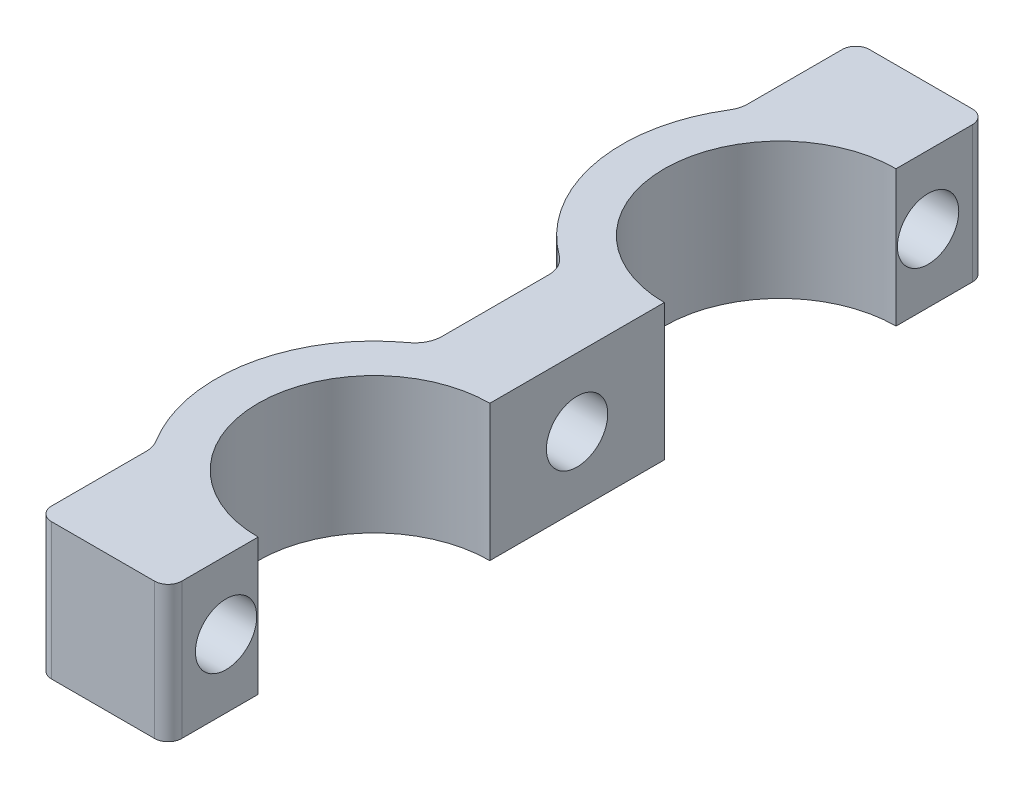
from build123d import *

# Parameters (mm, degrees)
EXTRUDE_1_DEPTH     = 10
EXTRUDE_2_DEPTH     = 10
EXTRUDE_4_DEPTH     = 10
SKETCH_3_R          = 2.25
CUT_EXTRUDE_4_DEPTH = 12.6
SKETCH_4_R          = 2.25
CUT_EXTRUDE_2_DEPTH = 7
FILLET_2_R          = 1
EXTRUDE_3_DEPTH     = 10
CUT_EXTRUDE_3_DEPTH = 11
FILLET_3_R          = 1
FILLET_4_R          = 2


with BuildPart() as part:
    # Эскиз1 → Бобышка-Вытянуть1 (new body)
    with BuildSketch(Plane(origin=(0, 0, 0), x_dir=(1, 0, 0), z_dir=(0, 1, 0))):
        with BuildLine():
            Line((0, 0), (0, 8))
            ThreePointArc((0, 8), (-7.1, 15.1), (0, 22.2))
            Line((0, 22.2), (0, 37.8))
            ThreePointArc((0, 37.8), (-7.1, 44.9), (0, 52))
            Line((0, 52), (0, 60))
            Line((0, 60), (-3, 60))
            Line((-3, 60), (-3, 54.544169223))
            ThreePointArc((-3, 54.544169223), (-10.1, 44.9), (-3, 35.255830777))
            Line((-3, 35.255830777), (-3, 24.744169223))
            ThreePointArc((-3, 24.744169223), (-10.1, 15.1), (-3, 5.455830777))
            Line((-3, 5.455830777), (-3, 0))
            Line((-3, 0), (0, 0))
        make_face()
    extrude(amount=EXTRUDE_1_DEPTH)

    # Эскиз2 → Бобышка-Вытянуть2 (add)
    with BuildSketch(Plane(origin=(0, 10, 0), x_dir=(1, 0, 0), z_dir=(0, 1, 0))):
        with BuildLine():
            Line((-3, 60), (-8.049844719, 60))
            Line((-8.049844719, 60), (-8.049844719, 51))
            ThreePointArc((-8.049844719, 51), (-5.802159163, 53.167100402), (-3, 54.544169223))
            Line((-3, 54.544169223), (-3, 60))
        make_face()
        with BuildLine():
            Line((-3, 0), (-3, 5.455830777))
            ThreePointArc((-3, 5.455830777), (-5.802159163, 6.832899598), (-8.049844719, 9))
            Line((-8.049844719, 9), (-8.049844719, 0))
            Line((-8.049844719, 0), (-3, 0))
        make_face()
    extrude(amount=-EXTRUDE_2_DEPTH)

    # Эскиз9 → Бобышка-Вытянуть4 (add, through all)
    with BuildSketch(Plane.XZ):
        with BuildLine():
            Line((-6, -25.027738917), (-6, -34.972261083))
            ThreePointArc((-6, -34.972261083), (-11.340897297, -42.461958059), (-9.549844719, -51.484866426))
            Line((-9.549844719, -51.484866426), (-9.549844719, -60))
            Line((-9.549844719, -60), (-8.049844719, -60))
            Line((-8.049844719, -60), (-8.049844719, -51))
            ThreePointArc((-8.049844719, -51), (-9.617405222, -41.81527687), (-3, -35.255830777))
            Line((-3, -35.255830777), (-3, -24.744169223))
            ThreePointArc((-3, -24.744169223), (-9.617405222, -18.18472313), (-8.049844719, -9))
            Line((-8.049844719, -9), (-8.049844719, 0))
            Line((-8.049844719, 0), (-9.549844719, 0))
            Line((-9.549844719, 0), (-9.549844719, -8.515133574))
            ThreePointArc((-9.549844719, -8.515133574), (-11.340897297, -17.538041941), (-6, -25.027738917))
        make_face()
    extrude(amount=-EXTRUDE_4_DEPTH)

    # Эскиз3 → Вырез-Вытянуть4 (cut, through all)
    with BuildSketch(Plane.ZY):
        with Locations((-55.75, 5)):
            Circle(SKETCH_3_R)
        with Locations((-4.25, 5)):
            Circle(SKETCH_3_R)
    extrude(amount=CUT_EXTRUDE_4_DEPTH, mode=Mode.SUBTRACT)

    # Эскиз4 → Вырез-Вытянуть2 (cut, through all)
    with BuildSketch(Plane.ZY.offset(6)):
        with Locations((-30, 5)):
            Circle(SKETCH_4_R)
    extrude(amount=-CUT_EXTRUDE_2_DEPTH, mode=Mode.SUBTRACT)

    # Скругление2
    fillet_2_edges = [part.edges().sort_by_distance(p)[0] for p in [
        (0, 5, -60),
        (0, 5, 0),
    ]]
    fillet(fillet_2_edges, radius=FILLET_2_R)

    # Эскиз5 → Бобышка-Вытянуть3 (add, through all)
    with BuildSketch(Plane.XZ):
        with BuildLine():
            Line((0, -8), (0, -8.1))
            ThreePointArc((0, -8.1), (-7, -15.1), (0, -22.1))
            Line((0, -22.1), (0, -22.2))
            ThreePointArc((0, -22.2), (-7.1, -15.1), (0, -8))
        make_face()
        with BuildLine():
            Line((0, -51.9), (0, -52))
            ThreePointArc((0, -52), (-7.1, -44.9), (0, -37.8))
            Line((0, -37.8), (0, -37.9))
            ThreePointArc((0, -37.9), (-7, -44.9), (0, -51.9))
        make_face()
    extrude(amount=-EXTRUDE_3_DEPTH)

    # Эскиз7 → Вырез-Вытянуть3 (cut, through all)
    with BuildSketch(Plane(origin=(0, 10, 0), x_dir=(1, 0, 0), z_dir=(0, 1, 0))):
        with BuildLine():
            Line((0, 51.9), (0, 53.4))
            ThreePointArc((0, 53.4), (-8.5, 44.9), (0, 36.4))
            Line((0, 36.4), (0, 37.9))
            ThreePointArc((0, 37.9), (-7, 44.9), (0, 51.9))
        make_face()
        with BuildLine():
            Line((0, 22.1), (0, 23.6))
            ThreePointArc((0, 23.6), (-8.5, 15.1), (0, 6.6))
            Line((0, 6.6), (0, 8.1))
            ThreePointArc((0, 8.1), (-7, 15.1), (0, 22.1))
        make_face()
    extrude(amount=-CUT_EXTRUDE_3_DEPTH, mode=Mode.SUBTRACT)

    # Скругление3
    fillet_3_edges = [part.edges().sort_by_distance(p)[0] for p in [
        (-9.549844719, 5, 0),
        (-9.549844719, 5, -60),
    ]]
    fillet(fillet_3_edges, radius=FILLET_3_R)

    # Скругление4
    fillet_4_edges = [part.edges().sort_by_distance(p)[0] for p in [
        (-9.549844719, 5, -8.515133574),
        (-9.549844719, 5, -51.484866426),
        (-6, 5, -34.972261083),
        (-6, 5, -25.027738917),
    ]]
    fillet(fillet_4_edges, radius=FILLET_4_R)


solid = part.part
